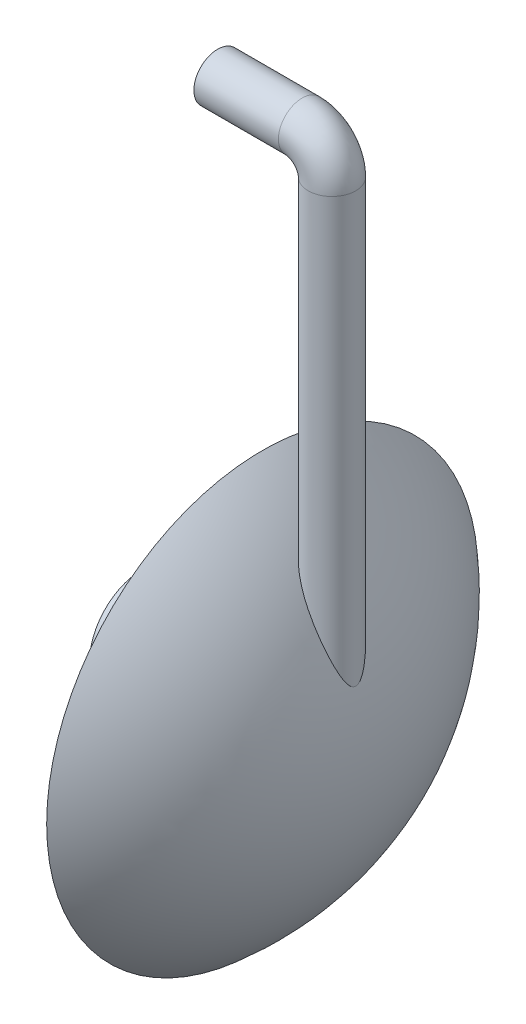
from build123d import *

# Parameters (mm, degrees)
SHELL3_T                        = -59.766763848
SKETCH6_R                       = 53.790087464
BOSS_EXTRUDE2_DEPTH             = 120
BOSS_EXTRUDE2_DIRECTION_2_REACH = 102
SKETCH5_R                       = 23.906705539
BOSS_EXTRUDE3_REACH             = 358.953


with BuildPart() as part:
    # Sketch2 → Revolve1 (revolve)
    with BuildSketch(Plane(origin=(0, 0, 0), x_dir=(1, 0, 0), z_dir=(0, 1, 0))):
        with BuildLine():
            Line((0, 0), (0, -216.95335277))
            ThreePointArc((0, -216.95335277), (73.796884119, -119.4453403), (100, 0))
            Line((100, 0), (0, 0))
        make_face()
    revolve(axis=Axis((100, 0, 0), (-1, 0, 0)))

    # Shell3
    shell3_openings = [part.faces().sort_by_distance(p)[0] for p in [
        (0, 0, -216.95335277),
    ]]
    offset(amount=SHELL3_T, openings=shell3_openings, kind=Kind.INTERSECTION)

    # Sketch6 → Boss-Extrude2 (add)
    with BuildSketch(Plane.ZY):
        Circle(SKETCH6_R)
    extrude(amount=BOSS_EXTRUDE2_DEPTH)

    # Sketch6 → Boss-Extrude2 direction 2 (add, up to next)
    with BuildSketch(Plane.ZY, mode=Mode.PRIVATE) as boss_extrude2_direction_2_sk1:
        Circle(SKETCH6_R)
    boss_extrude2_direction_2_tool1 = extrude(boss_extrude2_direction_2_sk1.sketch, amount=-BOSS_EXTRUDE2_DIRECTION_2_REACH, mode=Mode.PRIVATE) - part.part
    add(boss_extrude2_direction_2_tool1.solids().sort_by_distance((0, 0, 0))[0])

    # Sweep2: sweep along a path in Sketch4
    with BuildLine(Plane.XY) as sweep2_path:
        Line((75, 140), (75, 490))
        ThreePointArc((75, 490), (64.748737342, 514.748737342), (40, 525))
        Line((40, 525), (-45, 525))
    # Sketch5 → Sweep2 (sweep)
    with BuildSketch(Plane(origin=(0, 140, 0), x_dir=(1, 0, 0), z_dir=(0, 1, 0))):
        with Locations((70, 0)):
            Circle(SKETCH5_R)
    sweep(path=sweep2_path.line)

    # Sketch7 → Boss-Extrude3 (add, up to next)
    with BuildSketch(Plane.XZ.offset(-140), mode=Mode.PRIVATE) as boss_extrude3_sk1:
        with BuildLine():
            ThreePointArc((62.263560743, -22.620302327), (93.906705539, 0), (62.263560743, 22.620302327))
            ThreePointArc((62.263560743, 22.620302327), (63.29465881, 0), (62.263560743, -22.620302327))
        make_face()
    boss_extrude3_tool1 = extrude(boss_extrude3_sk1.sketch, amount=BOSS_EXTRUDE3_REACH, mode=Mode.PRIVATE) - part.part
    add(boss_extrude3_tool1.solids().sort_by_distance((76.458638, 140, 0))[0])


solid = part.part
